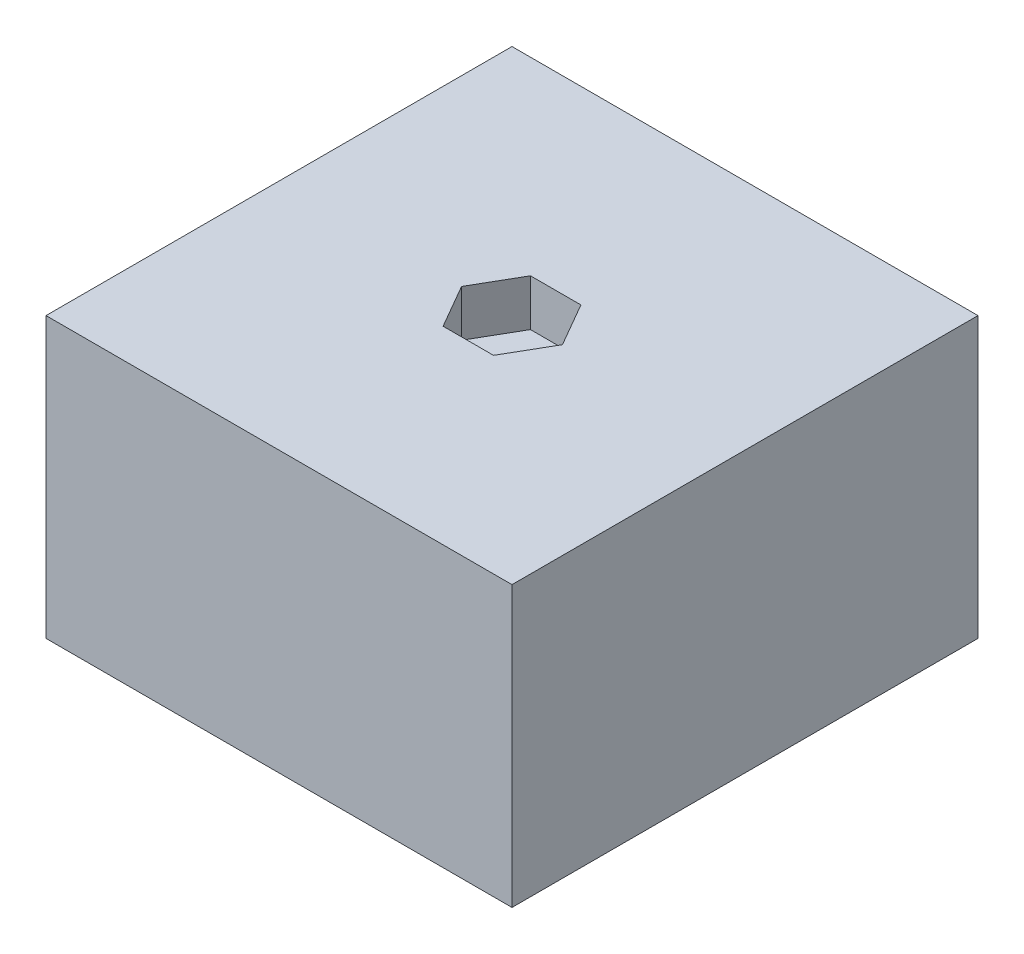
from build123d import *

# Parameters (mm, degrees)
SKETCH1_W           = 12.7
SKETCH1_H           = 12.7
BOSS_EXTRUDE1_DEPTH = 7.62
CUT_EXTRUDE1_DEPTH  = 1.27


with BuildPart() as part:
    # Sketch1 → Boss-Extrude1 (new body)
    with BuildSketch(Plane(origin=(0, 0, 0), x_dir=(1, 0, 0), z_dir=(0, 1, 0))):
        Rectangle(SKETCH1_W, SKETCH1_H)
    extrude(amount=BOSS_EXTRUDE1_DEPTH)

    # Sketch2 → Cut-Extrude1 (cut)
    with BuildSketch(Plane(origin=(0, 7.62, 0), x_dir=(1, 0, 0), z_dir=(0, 1, 0))):
        Polygon((0.687407664, -1.190625), (1.374815329, 0), (0.687407664, 1.190625), (-0.687407664, 1.190625), (-1.374815329, 0), (-0.687407664, -1.190625), align=None)
    extrude(amount=-CUT_EXTRUDE1_DEPTH, mode=Mode.SUBTRACT)


solid = part.part
